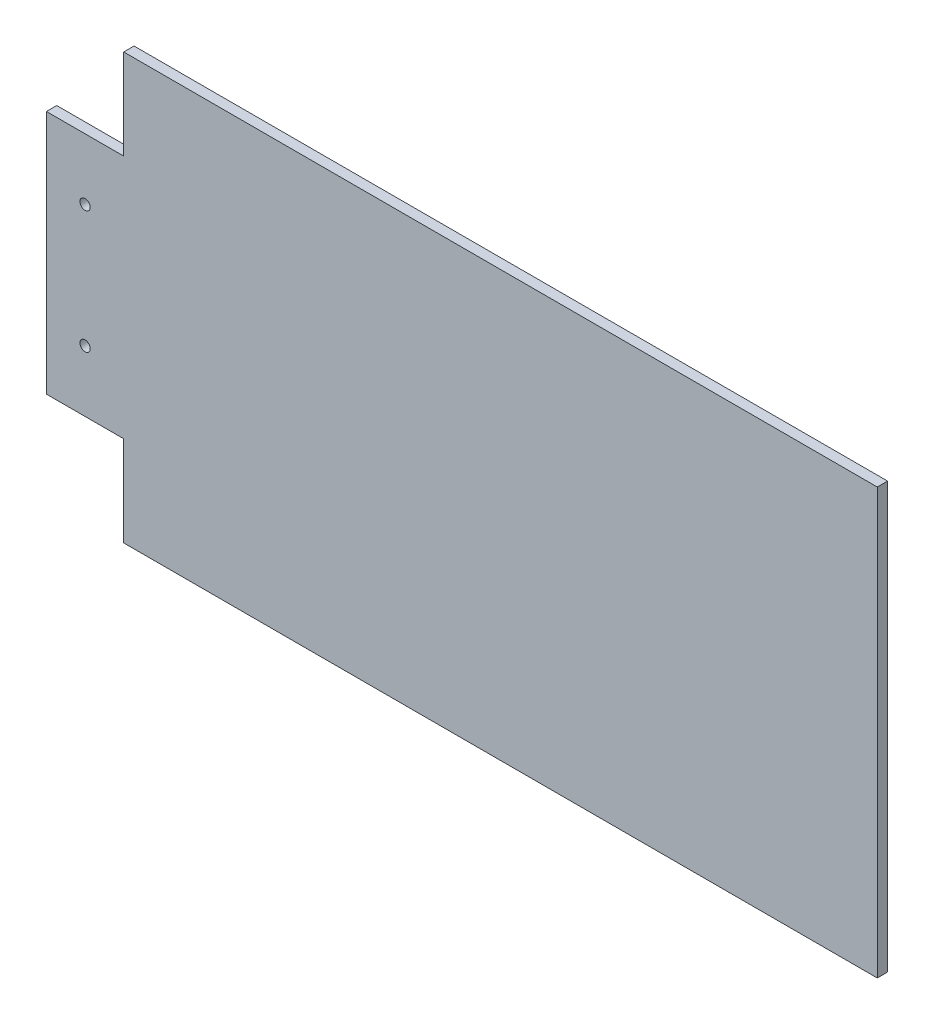
from build123d import *

# Parameters (mm, degrees)
SKETCH1_R           = 2
BOSS_EXTRUDE1_DEPTH = 4


with BuildPart() as part:
    # Sketch1 → Boss-Extrude1 (new body)
    with BuildSketch(Plane.XY):
        Polygon((1290.348495848, 1267.221190617), (1320.348495847, 1267.221190617), (1320.348495847, 1302.221190774), (1612.748495862, 1302.221190774), (1612.748495862, 1137.221190551), (1320.348495847, 1137.221190551), (1320.348495847, 1172.221190551), (1290.348495848, 1172.221190551), align=None)
        with Locations((1305.348520336, 1243.471190636)):
            Circle(SKETCH1_R, mode=Mode.SUBTRACT)
        with Locations((1305.348520336, 1195.971190682)):
            Circle(SKETCH1_R, mode=Mode.SUBTRACT)
    extrude(amount=BOSS_EXTRUDE1_DEPTH)


solid = part.part
